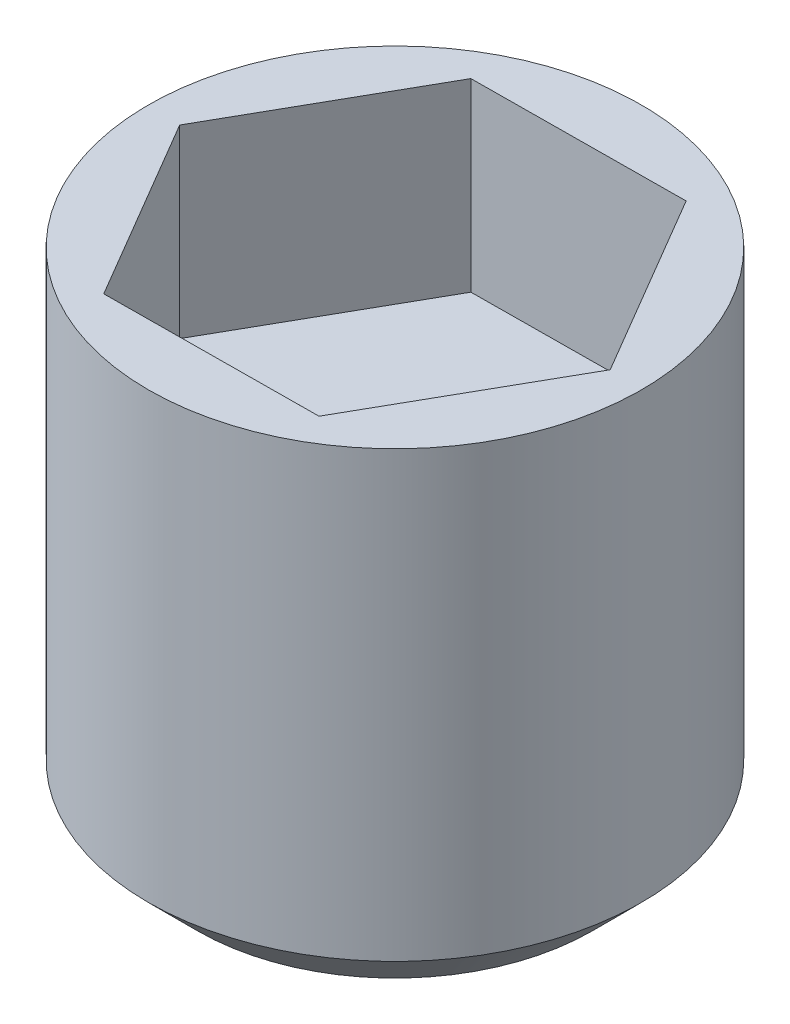
from build123d import *

# Parameters (mm, degrees)
CUT_EXTRUDE_1_DEPTH = 3


with BuildPart() as part:
    # Эскиз1 → Повернуть1 (revolve)
    with BuildSketch(Plane.XY):
        Polygon((0, 0), (3.2, 0), (4, 0.8), (4, 8), (0, 8), align=None)
    revolve(axis=Axis((0, 68.644575989, 0), (0, -1, 0)))

    # Эскиз2 → Вырез-Вытянуть1 (cut)
    with BuildSketch(Plane(origin=(0, 8, 0), x_dir=(1, 0, 0), z_dir=(0, 1, 0))):
        Polygon((1.755265403, -2.986476748), (3.463997433, 0.026866056), (1.708732029, 3.013342804), (-1.755265403, 2.986476748), (-3.463997433, -0.026866056), (-1.708732029, -3.013342804), align=None)
    extrude(amount=-CUT_EXTRUDE_1_DEPTH, mode=Mode.SUBTRACT)


solid = part.part
